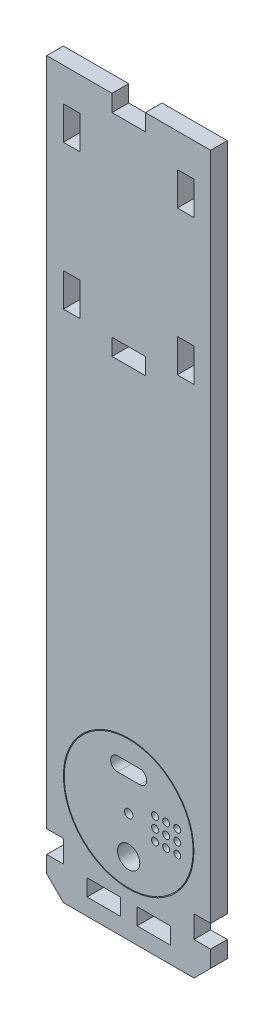
from build123d import *

# Parameters (mm, degrees)
SKETCH1_R             = 23.2
SKETCH1_R_2           = 4
SKETCH1_R_3           = 1.25
SKETCH1_R_4           = 1.5
BOSS_EXTRUDE1_DEPTH   = 6
SKETCH1_W             = 59
SKETCH1_H             = 255
SKETCH1_R_5           = 23.5
BOSS_EXTRUDE1_2_DEPTH = 6
SKETCH3_W             = 6
SKETCH3_H             = 8
SKETCH3_H_2           = 12
SKETCH3_W_2           = 12
SKETCH3_H_3           = 6
CUT_EXTRUDE1_DEPTH    = 10
BOSS_EXTRUDE3_DEPTH   = 6


with BuildPart() as part:
    # Sketch1 → Boss-Extrude1 (new body)
    with BuildSketch(Plane.XY):
        with Locations((0, 33.5)):
            Circle(SKETCH1_R)
        with Locations((0, 20)):
            Circle(SKETCH1_R_2, mode=Mode.SUBTRACT)
        with Locations((9.5, 29.5)):
            Circle(SKETCH1_R_3, mode=Mode.SUBTRACT)
        with Locations((13.5, 29.5)):
            Circle(SKETCH1_R_3, mode=Mode.SUBTRACT)
        with Locations((17.5, 29.5)):
            Circle(SKETCH1_R_3, mode=Mode.SUBTRACT)
        with Locations((13.5, 33.5)):
            Circle(SKETCH1_R_3, mode=Mode.SUBTRACT)
        with Locations((17.5, 33.5)):
            Circle(SKETCH1_R_3, mode=Mode.SUBTRACT)
        with Locations((17.5, 37.5)):
            Circle(SKETCH1_R_3, mode=Mode.SUBTRACT)
        with Locations((13.5, 37.5)):
            Circle(SKETCH1_R_3, mode=Mode.SUBTRACT)
        with Locations((9.5, 37.5)):
            Circle(SKETCH1_R_3, mode=Mode.SUBTRACT)
        with Locations((9.5, 33.5)):
            Circle(SKETCH1_R_3, mode=Mode.SUBTRACT)
        with Locations((0, 33.5)):
            Circle(SKETCH1_R_4, mode=Mode.SUBTRACT)
        with BuildLine():
            Line((-4, 49.5), (4, 49.5))
            ThreePointArc((4, 49.5), (6.5, 47), (4, 44.5))
            Line((4, 44.5), (-4, 44.5))
            ThreePointArc((-4, 44.5), (-6.5, 47), (-4, 49.5))
        make_face(mode=Mode.SUBTRACT)
    extrude(amount=-BOSS_EXTRUDE1_DEPTH)


with BuildPart() as body_2:
    # Sketch1 → Boss-Extrude1 2 (new body)
    with BuildSketch(Plane.XY):
        with Locations((0, 127.5)):
            Rectangle(SKETCH1_W, SKETCH1_H)
        with Locations((0, 33.5)):
            Circle(SKETCH1_R_5, mode=Mode.SUBTRACT)
    extrude(amount=-BOSS_EXTRUDE1_2_DEPTH)

    # Sketch3 → Cut-Extrude1 (cut)
    with BuildSketch(Plane.XY):
        with Locations((-26.5, 10)):
            Rectangle(SKETCH3_W, SKETCH3_H)
        with Locations((26.5, 10)):
            Rectangle(SKETCH3_W, SKETCH3_H)
        with Locations((20.5, 237)):
            Rectangle(SKETCH3_W, SKETCH3_H_2)
        with Locations((20.5, 185)):
            Rectangle(SKETCH3_W, SKETCH3_H_2)
        with Locations((0, 176)):
            Rectangle(SKETCH3_W_2, SKETCH3_H_3)
        with Locations((-20.5, 185)):
            Rectangle(SKETCH3_W, SKETCH3_H_2)
        with Locations((-20.5, 237)):
            Rectangle(SKETCH3_W, SKETCH3_H_2)
        with Locations((0, 252)):
            Rectangle(SKETCH3_W_2, SKETCH3_H_3)
        with Locations((-9, 3)):
            Rectangle(SKETCH3_W_2, SKETCH3_H_3)
        with Locations((9, 3)):
            Rectangle(SKETCH3_W_2, SKETCH3_H_3)
    extrude(amount=-CUT_EXTRUDE1_DEPTH, mode=Mode.SUBTRACT)

    # Sketch5 → Boss-Extrude3 (add)
    with BuildSketch(Plane.XY):
        Polygon((-29.5, 0), (-23.5, 0), (23.5, 0), (29.5, 0), (23.5, -6), (-23.5, -6), align=None)
    extrude(amount=-BOSS_EXTRUDE3_DEPTH)


solid = Compound([part.part, body_2.part])
